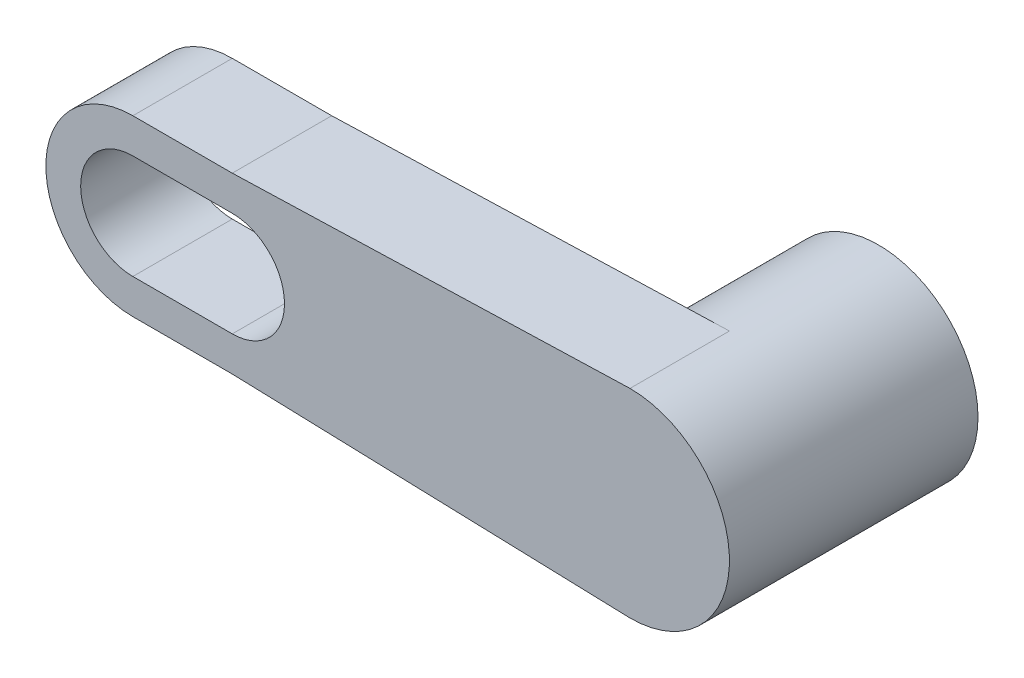
from build123d import *
from build123d.topology import SkipClean

# Parameters (mm, degrees)
BOSS_EXTRU_1_DEPTH      = 4
ESQUISSE2_R             = 4
BOSS_EXTRU_2_DEPTH      = 6
ENL_V_START             = -6
ESQUISSE3_R             = 2.5
ENL_V_MAT_EXTRU_1_DEPTH = 5


with BuildPart() as part:
    # Esquisse1 → Boss.-Extru.1 (new body)
    with BuildSketch(Plane.XY):
        with BuildLine():
            Line((2, -3.5), (-2, -3.5))
            ThreePointArc((-2, -3.5), (-5.5, 0), (-2, 3.5))
            Line((-2, 3.5), (2, 3.5))
            Line((2, 3.5), (18, 4))
            ThreePointArc((18, 4), (22, 0), (18, -4))
            Line((18, -4), (2, -3.5))
        make_face()
        with BuildLine():
            Line((-2, 2.1), (2, 2.1))
            ThreePointArc((2, 2.1), (4.1, 0), (2, -2.1))
            Line((2, -2.1), (-2, -2.1))
            ThreePointArc((-2, -2.1), (-4.1, 0), (-2, 2.1))
        make_face(mode=Mode.SUBTRACT)
    extrude(amount=BOSS_EXTRU_1_DEPTH)

    # Esquisse2 → Boss.-Extru.2 (add)
    with SkipClean():  # the faces are left unmerged after this step: merging them gives an invalid solid
        with BuildSketch(Plane.XY):
            with Locations(Location((18, 0, 0), (0, 0, 266.420178784))):
                Circle(ESQUISSE2_R)
        extrude(amount=-BOSS_EXTRU_2_DEPTH)

    # Esquisse3 → Enl_v. mat.-Extru.1 (cut)
    with SkipClean():  # the faces are left unmerged after this step: merging them gives an invalid solid
        with BuildSketch(Plane.XY.offset(ENL_V_START)):
            with Locations((18, 0)):
                Circle(ESQUISSE3_R)
        extrude(amount=ENL_V_MAT_EXTRU_1_DEPTH, mode=Mode.SUBTRACT)


solid = part.part
